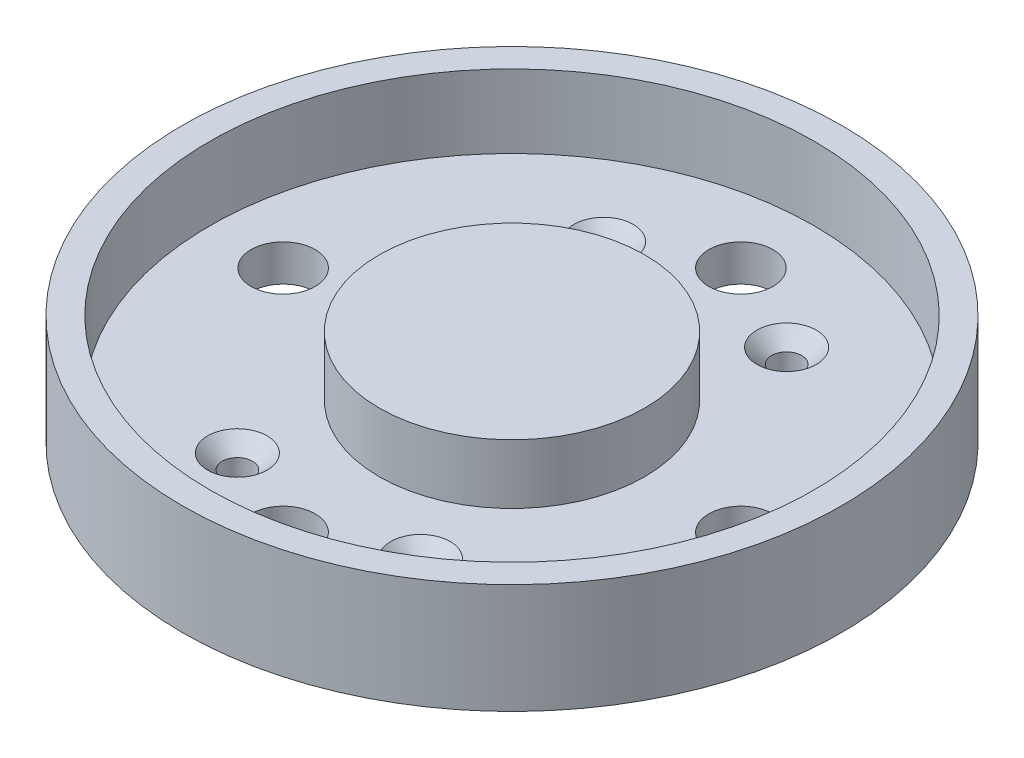
from build123d import *

# Parameters (mm, degrees)
SKETCH1_R           = 36
SKETCH1_R_2         = 3.5
SKETCH1_R_3         = 1.65
BOSS_EXTRUDE1_DEPTH = 4
SKETCH2_R           = 14.5
BOSS_EXTRUDE2_DEPTH = 6.5
SKETCH3_R           = 36
SKETCH3_R_2         = 33
BOSS_EXTRUDE3_DEPTH = 8
CHAMFER1_SIZE       = 1.6


with BuildPart() as part:
    # Sketch1 → Boss-Extrude1 (new body)
    with BuildSketch(Plane(origin=(0, 0, 0), x_dir=(1, 0, 0), z_dir=(0, 1, 0))):
        Circle(SKETCH1_R)
        with Locations((25, 0)):
            Circle(SKETCH1_R_2, mode=Mode.SUBTRACT)
        with Locations((0, -25)):
            Circle(SKETCH1_R_2, mode=Mode.SUBTRACT)
        with Locations((-10, 20)):
            Circle(SKETCH1_R_3, mode=Mode.SUBTRACT)
        with Locations((10, 20)):
            Circle(SKETCH1_R_3, mode=Mode.SUBTRACT)
        with Locations((10, -20)):
            Circle(SKETCH1_R_3, mode=Mode.SUBTRACT)
        with Locations((-10, -20)):
            Circle(SKETCH1_R_3, mode=Mode.SUBTRACT)
        with Locations((0, 25)):
            Circle(SKETCH1_R_2, mode=Mode.SUBTRACT)
        with Locations((-25, 0)):
            Circle(SKETCH1_R_2, mode=Mode.SUBTRACT)
    extrude(amount=BOSS_EXTRUDE1_DEPTH)

    # Sketch2 → Boss-Extrude2 (add)
    with BuildSketch(Plane(origin=(0, 4, 0), x_dir=(1, 0, 0), z_dir=(0, 1, 0))):
        Circle(SKETCH2_R)
    extrude(amount=BOSS_EXTRUDE2_DEPTH)

    # Sketch3 → Boss-Extrude3 (add)
    with BuildSketch(Plane(origin=(0, 4, 0), x_dir=(1, 0, 0), z_dir=(0, 1, 0))):
        Circle(SKETCH3_R)
        Circle(SKETCH3_R_2, mode=Mode.SUBTRACT)
    extrude(amount=BOSS_EXTRUDE3_DEPTH)

    # Chamfer1
    chamfer1_edges = [part.edges().sort_by_distance(p)[0] for p in [
        (8.35, 4, -20),
        (8.35, 4, 20),
        (-11.65, 4, 20),
        (-11.65, 4, -20),
    ]]
    chamfer(chamfer1_edges, length=CHAMFER1_SIZE)


solid = part.part
